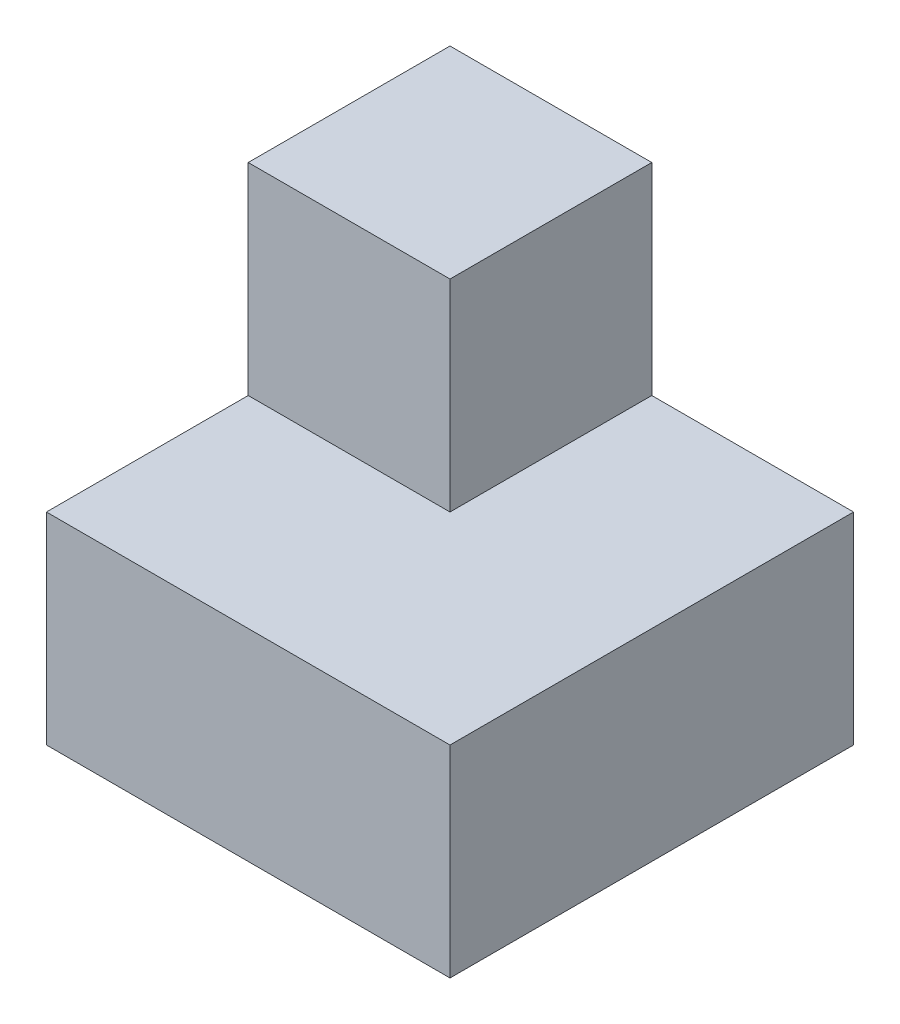
from build123d import *

# Parameters (mm, degrees)
SKETCH1_W           = 4
SKETCH1_H           = 4
BOSS_EXTRUDE1_DEPTH = 4
CUT_EXTRUDE1_DEPTH  = 2


with BuildPart() as part:
    # Sketch1 → Boss-Extrude1 (new body)
    with BuildSketch(Plane(origin=(0, 0, 0), x_dir=(1, 0, 0), z_dir=(0, 1, 0))):
        with Locations((2, 2)):
            Rectangle(SKETCH1_W, SKETCH1_H)
    extrude(amount=BOSS_EXTRUDE1_DEPTH)

    # Sketch2 → Cut-Extrude1 (cut)
    with BuildSketch(Plane(origin=(0, 4, 0), x_dir=(1, 0, 0), z_dir=(0, 1, 0))):
        Polygon((4, 4), (2, 4), (2, 2), (0, 2), (0, 0), (4, 0), align=None)
    extrude(amount=-CUT_EXTRUDE1_DEPTH, mode=Mode.SUBTRACT)


solid = part.part
